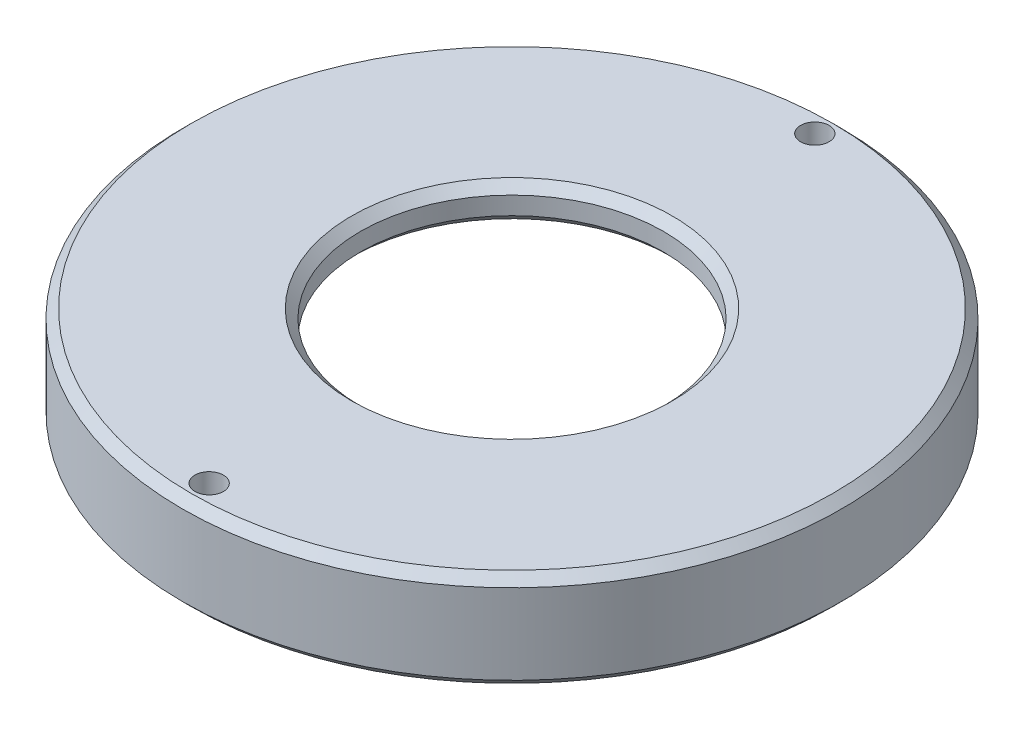
from build123d import *

# Parameters (mm, degrees)
CHAMFER1_SIZE             = 0.5
M2X0_4_TAPPED_HOLE1_D     = 1.6
M2X0_4_TAPPED_HOLE1_DEPTH = 15.2
M2X0_4_TAPPED_HOLE1_TIP   = 0.480688495


with BuildPart() as part:
    # Sketch2 → Revolve1 (revolve)
    with BuildSketch(Plane.XY, mode=Mode.PRIVATE) as revolve1_sk:
        Polygon((15.5, 0), (15.5, -3.5), (18.5, -3.5), (18.5, 2), (8.5, 2), (8.5, 0), align=None)
    revolve(revolve1_sk.sketch.rotate(Axis((0, 0, 0), (0, 1, 0)), 90), axis=Axis((0, 0, 0), (0, 1, 0)))  # turned: the seam where the file's is

    # Chamfer1
    chamfer1_edges = [part.edges().sort_by_distance(p)[0] for p in [
        (0, 0, 8.5),
        (0, 0, 15.5),
        (0, -3.5, 15.5),
        (0, -3.5, 18.5),
        (0, 2, 18.5),
        (0, 2, 8.5),
    ]]
    chamfer(chamfer1_edges, length=CHAMFER1_SIZE)

    # M2x0.4 Tapped Hole1
    with Locations(Plane(origin=(0, -3.5, 17), x_dir=(0, 0, -1), z_dir=(0, -1, 0))):
        with Locations((0, 0), (34, 0)):
            Hole(M2X0_4_TAPPED_HOLE1_D / 2, depth=M2X0_4_TAPPED_HOLE1_DEPTH)
            with Locations((0, 0, -(M2X0_4_TAPPED_HOLE1_DEPTH + M2X0_4_TAPPED_HOLE1_TIP / 2))):  # 118° drill point
                Cone(0, M2X0_4_TAPPED_HOLE1_D / 2, M2X0_4_TAPPED_HOLE1_TIP, mode=Mode.SUBTRACT)


solid = part.part
